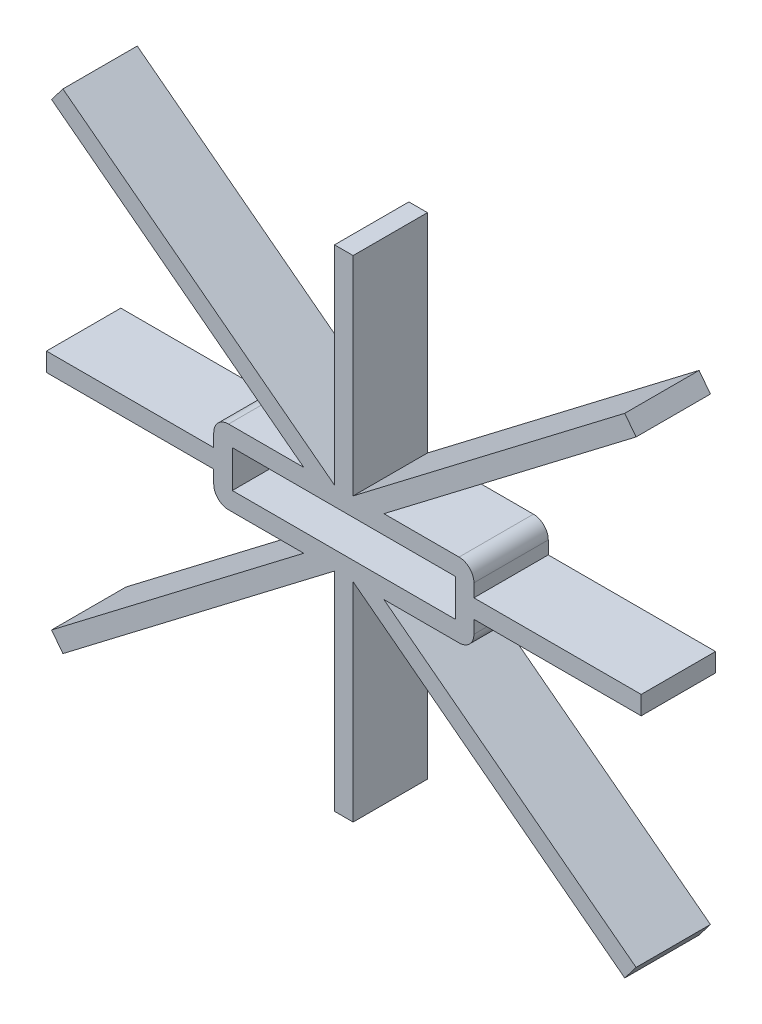
from build123d import *

# Parameters (mm, degrees)
SKETCH1_W           = 76.2
SKETCH1_H           = 12.7
BOSS_EXTRUDE1_DEPTH = 25.4
FILLET1_R           = 5.08


with BuildPart() as part:
    # Sketch1 → Boss-Extrude1 (new body)
    with BuildSketch(Plane.XY):
        Polygon((44.45, 12.7), (13.6906, 12.7), (99.855246, 78.474538932), (95.983665425, 83.546309485), (3.175, 12.7), (3.175, 83.82), (-3.175, 83.82), (-3.175, 12.7), (-95.983665425, 83.546309485), (-99.855246, 78.474538932), (-13.6906, 12.7), (-44.45, 12.7), (-44.45, 3.175), (-101.6, 3.175), (-101.6, -3.175), (-44.45, -3.175), (-44.45, -12.7), (-13.6906, -12.7), (-99.855246, -78.474538932), (-95.983665425, -83.546309485), (-3.175, -12.7), (-3.175, -83.82), (3.175, -83.82), (3.175, -12.7), (95.983665425, -83.546309485), (99.855246, -78.474538932), (13.6906, -12.7), (44.45, -12.7), (44.45, -3.175), (101.6, -3.175), (101.6, 3.175), (44.45, 3.175), align=None)
        Rectangle(SKETCH1_W, SKETCH1_H, mode=Mode.SUBTRACT)
    extrude(amount=BOSS_EXTRUDE1_DEPTH)

    # Fillet1
    fillet1_edges = [part.edges().sort_by_distance(p)[0] for p in [
        (44.45, 12.7, 12.7),
        (44.45, -12.7, 12.7),
        (-44.45, -12.7, 12.7),
        (-44.45, 12.7, 12.7),
    ]]
    fillet(fillet1_edges, radius=FILLET1_R)


solid = part.part
